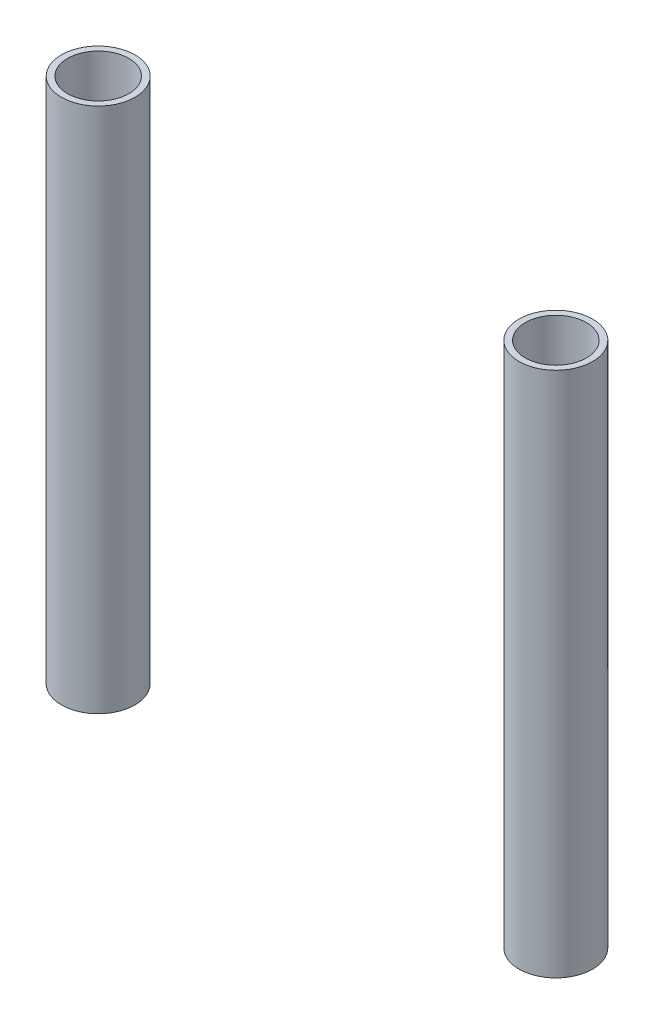
from build123d import *

# Parameters (mm, degrees)
SKETCH1_R             = 8.038978159
SKETCH1_R_2           = 6.692778159
BOSS_EXTRUDE1_DEPTH   = 115
BOSS_EXTRUDE1_2_DEPTH = 115


with BuildPart() as part:
    # Sketch1 → Boss-Extrude1 (new body)
    with BuildSketch(Plane(origin=(0, 0, 0), x_dir=(1, 0, 0), z_dir=(0, 1, 0))):
        with Locations((-50, 0)):
            Circle(SKETCH1_R)
        with Locations((-50, 0)):
            Circle(SKETCH1_R_2, mode=Mode.SUBTRACT)
    extrude(amount=BOSS_EXTRUDE1_DEPTH)


with BuildPart() as body_2:
    # Sketch1 → Boss-Extrude1 2 (new body)
    with BuildSketch(Plane(origin=(0, 0, 0), x_dir=(1, 0, 0), z_dir=(0, 1, 0))):
        with Locations((50, 0)):
            Circle(SKETCH1_R)
        with Locations((50, 0)):
            Circle(SKETCH1_R_2, mode=Mode.SUBTRACT)
    extrude(amount=BOSS_EXTRUDE1_2_DEPTH)


solid = Compound([part.part, body_2.part])
